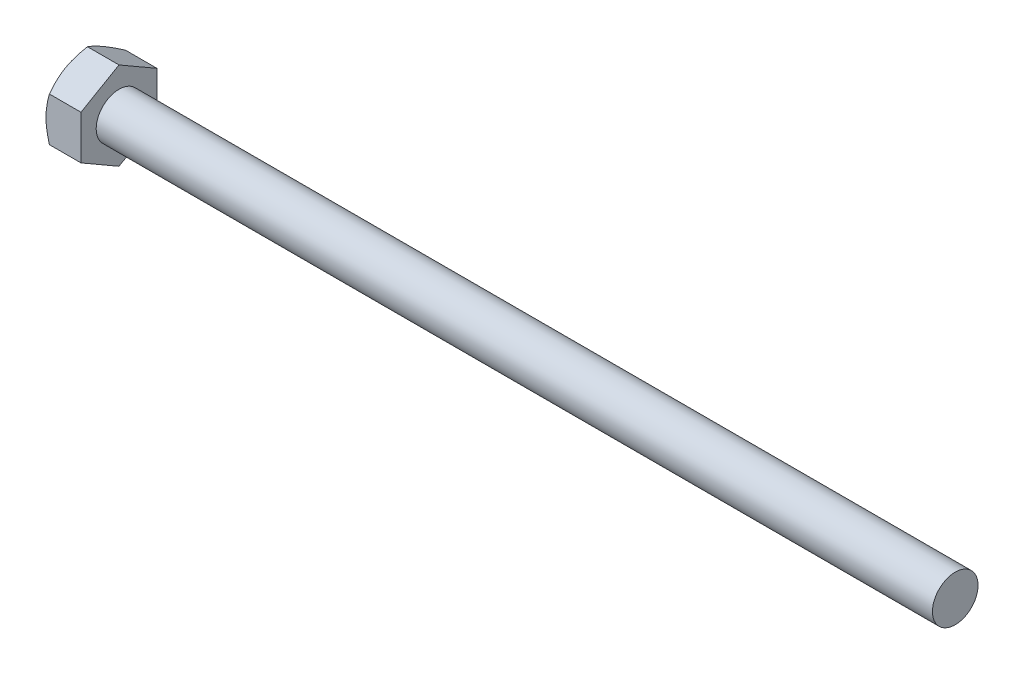
from build123d import *

# Parameters (mm, degrees)
SKETCH2_R     = 2.915704388
HEX_DIE_DEPTH = 2.3
SKETCH4_R     = 2.1875
INDENT_DEPTH  = 0.2875


with BuildPart() as part:
    # BodySke → Base-Revolve (revolve)
    with BuildSketch(Plane.XY):
        Polygon((2.3, 1.5), (2.3, 2.886836028), (0.223339885, 2.886836028), (0, 2.5), (0, 0), (57.3, 0), (57.3, 1.5), align=None)
    revolve(axis=Axis((-25.4, 0, 0), (1, 0, 0)))

    # Sketch2 → Hex-Die (cut)
    with BuildSketch(Plane(origin=(0, 0, 0), x_dir=(0, 0, -1), z_dir=(1, 0, 0))):
        Circle(SKETCH2_R)
        Polygon((-2.5, 1.443375679), (0, 2.886751359), (2.5, 1.443375679), (2.5, -1.443375679), (0, -2.886751359), (-2.5, -1.443375679), align=None, mode=Mode.SUBTRACT)
    extrude(amount=HEX_DIE_DEPTH, mode=Mode.SUBTRACT)

    # Sketch4 → Indent (cut)
    with BuildSketch(Plane(origin=(0, 0, 0), x_dir=(0, 0, -1), z_dir=(1, 0, 0))):
        Circle(SKETCH4_R)
    extrude(amount=INDENT_DEPTH, mode=Mode.SUBTRACT)


solid = part.part
